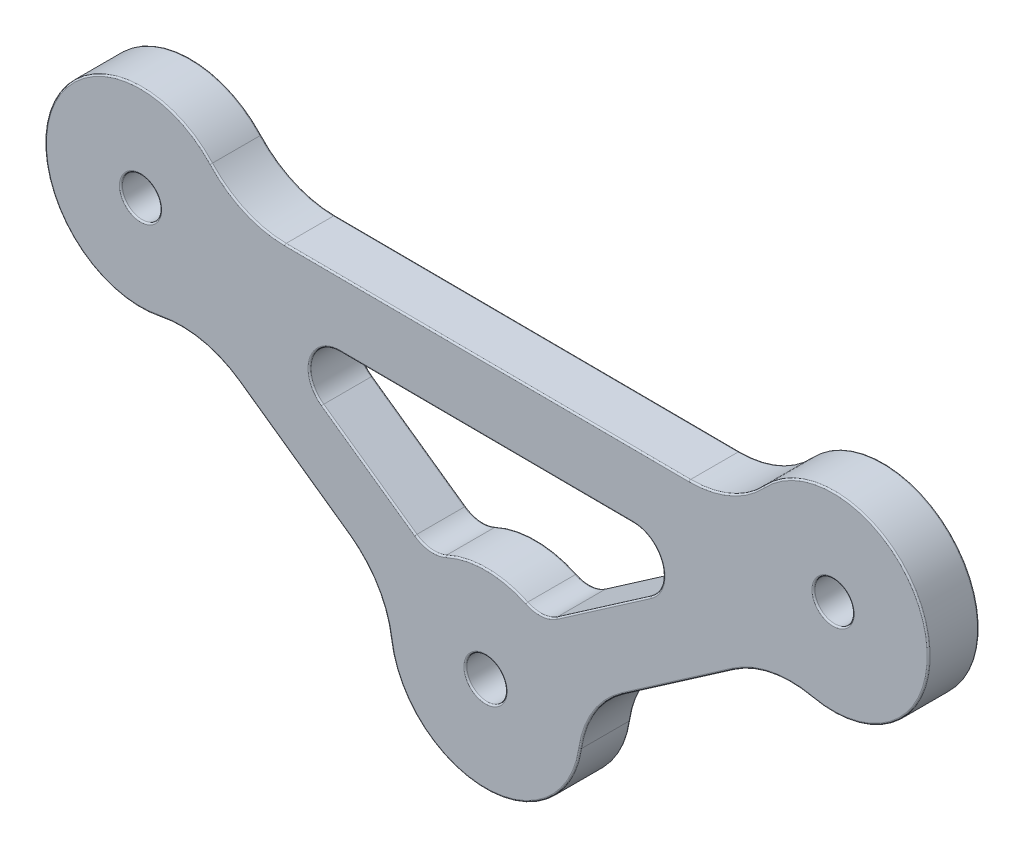
from build123d import *

# Parameters (mm, degrees)
SKETCH1_R             = 9.5
SKETCH1_R_2           = 1.95
BOSS_EXTRUDE1_DEPTH   = 5
SKETCH1_R_3           = 2
BOSS_EXTRUDE1_2_DEPTH = 5
BOSS_EXTRUDE1_3_DEPTH = 5
EXTRUDE_THIN1_DEPTH   = 5
FILLET1_R             = 3
FILLET2_R             = 10
FILLET3_R             = 0.15


with BuildPart() as part:
    # Sketch1 → Boss-Extrude1 (new body)
    with BuildSketch(Plane.XY):
        with Locations((-71.352572296, 303.213089234)):
            Circle(SKETCH1_R)
        with Locations((-71.352572296, 303.213089234)):
            Circle(SKETCH1_R_2, mode=Mode.SUBTRACT)
    extrude(amount=-BOSS_EXTRUDE1_DEPTH)



with BuildPart() as body_2:
    # Sketch1 → Boss-Extrude1 2 (new body)
    with BuildSketch(Plane.XY):
        with Locations((-37.077654746, 278.93902845)):
            Circle(SKETCH1_R)
        with Locations((-37.077654746, 278.93902845)):
            Circle(SKETCH1_R_3, mode=Mode.SUBTRACT)
    extrude(amount=-BOSS_EXTRUDE1_2_DEPTH)


with BuildPart() as body_3:
    # Sketch1 → Boss-Extrude1 3 (new body)
    with BuildSketch(Plane.XY):
        with Locations((-2.544786738, 302.844697802)):
            Circle(SKETCH1_R)
        with Locations((-2.544786738, 302.844697802)):
            Circle(SKETCH1_R_2, mode=Mode.SUBTRACT)
    extrude(amount=-BOSS_EXTRUDE1_3_DEPTH)


with BuildPart() as part_1:
    add(part.part)

    add(body_2.part)  # Extrude-Thin1 merges body 2

    add(body_3.part)  # Extrude-Thin1 merges body 3
    # Sketch2 → Extrude-Thin1 (add)
    with BuildSketch(Plane.XY):
        Polygon((-68.334505444, 297.093140502), (-43.85242148, 279.754525657), (-40.095721597, 285.058977182), (-64.577805561, 302.397592028), align=None)
        Polygon((-64.46607951, 299.926172918), (-9.46607951, 299.631707276), (-9.431279524, 306.131614118), (-64.431279524, 306.42607976), align=None)
        Polygon((-9.327897058, 302.101788395), (-33.994231349, 285.026310287), (-30.294544426, 279.681937857), (-5.628210134, 296.757415965), align=None)
    extrude(amount=-EXTRUDE_THIN1_DEPTH)

    # Fillet1
    fillet1_edges = [part_1.edges().sort_by_distance(p)[0] for p in [
        (-42.484181905, 286.750524087, -2.5),
        (-61.06243691, 299.907950085, -2.5),
        (-12.86972211, 299.649930108, -2.5),
        (-31.587795668, 286.692185698, -2.5),
    ]]
    fillet(fillet1_edges, radius=FILLET1_R)

    # Fillet2
    fillet2_edges = [part_1.edges().sort_by_distance(p)[0] for p in [
        (-65.946045137, 295.401593597, -2.5),
        (-46.240881788, 281.446072561, -2.5),
        (-62.408514705, 306.415250038, -2.5),
        (-11.454044342, 306.142443841, -2.5),
        (-8.034645815, 295.091540554, -2.5),
        (-27.888108745, 281.347813269, -2.5),
    ]]
    fillet(fillet2_edges, radius=FILLET2_R)

    # Fillet3
    fillet3_edges = [part_1.edges().sort_by_distance(p)[0] for p in [
        (-48.665613897, 291.128315972, -5),
        (-48.665613897, 291.128315972, 0),
        (-36.96607951, 299.778940097, 0),
        (-36.96607951, 299.778940097, -5),
        (-25.359842683, 291.003538719, -5),
        (-25.359842683, 291.003538719, 0),
        (-37.026793227, 288.438892297, -5),
        (-37.026793227, 288.438892297, 0),
        (-54.420130451, 297.774475034, 0),
        (-54.420130451, 297.774475034, -5),
        (-19.534492041, 297.58770009, -5),
        (-19.534492041, 297.58770009, 0),
        (-31.488886236, 287.249489404, 0),
        (-31.488886236, 287.249489404, -5),
        (-42.577118318, 287.30885492, -5),
        (-42.577118318, 287.30885492, 0),
        (-37.128516264, 269.439164604, -5),
        (-37.128516264, 269.439164604, 0),
        (-56.093463462, 288.423833079, 0),
        (-56.093463462, 288.423833079, -5),
        (-80.397459123, 306.118260879, 0),
        (-80.397459123, 306.118260879, -5),
        (-17.96137728, 288.219676911, -5),
        (-17.96137728, 288.219676911, 0),
        (6.530688796, 305.652854463, 0),
        (6.530688796, 305.652854463, -5),
        (-36.931279524, 306.278846939, 0),
        (-36.931279524, 306.278846939, -5),
        (-47.847852179, 281.559429504, -5),
        (-47.847852179, 281.559429504, 0),
        (-65.305699691, 293.923364473, -5),
        (-65.305699691, 293.923364473, 0),
        (-26.280016704, 281.443957022, 0),
        (-26.280016704, 281.443957022, -5),
        (-8.690782741, 293.620252694, -5),
        (-8.690782741, 293.620252694, 0),
        (-12.826462016, 306.986051191, -5),
        (-12.826462016, 306.986051191, 0),
        (-61.027142753, 307.244113816, -5),
        (-61.027142753, 307.244113816, 0),
        (-39.077654746, 278.93902845, -5),
        (-39.077654746, 278.93902845, 0),
        (-73.302572296, 303.213089234, -5),
        (-73.302572296, 303.213089234, 0),
        (-4.494786738, 302.844697802, -5),
        (-4.494786738, 302.844697802, 0),
    ]]
    fillet(fillet3_edges, radius=FILLET3_R)


solid = part_1.part
